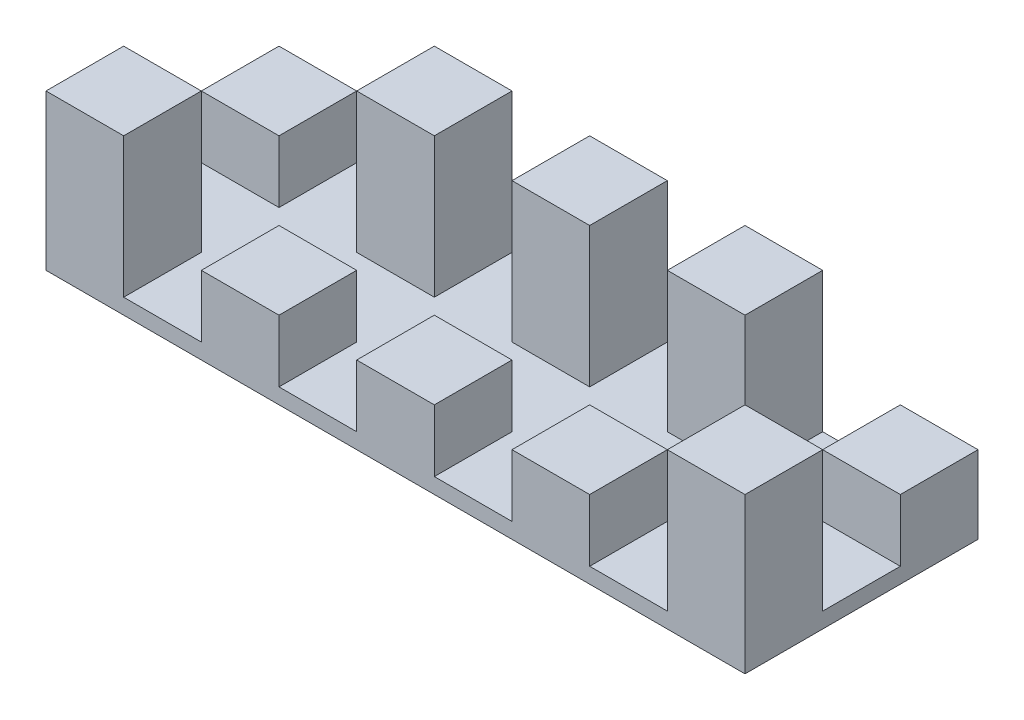
from build123d import *

# Parameters (mm, degrees)
SKETCH2_W             = 500
SKETCH2_H             = 500
BOSS_EXTRUDE1_DEPTH   = 500
BOSS_EXTRUDE1_2_DEPTH = 500
BOSS_EXTRUDE1_3_DEPTH = 500
BOSS_EXTRUDE1_4_DEPTH = 500
BOSS_EXTRUDE1_5_DEPTH = 500
SKETCH2_3_W           = 500
SKETCH2_3_H           = 500
BOSS_EXTRUDE2_DEPTH   = 1000
BOSS_EXTRUDE2_2_DEPTH = 1000
BOSS_EXTRUDE2_3_DEPTH = 1000
BOSS_EXTRUDE2_4_DEPTH = 1000
BOSS_EXTRUDE2_5_DEPTH = 1000
BOSS_EXTRUDE3_DEPTH   = 100


with BuildPart() as part:
    # Sketch2 → Boss-Extrude1 (new body)
    with BuildSketch(Plane(origin=(0, 0, 0), x_dir=(1, 0, 0), z_dir=(0, 1, 0))):
        with Locations((250, 1250)):
            Rectangle(SKETCH2_W, SKETCH2_H)
    extrude(amount=BOSS_EXTRUDE1_DEPTH)



with BuildPart() as body_2:
    # Sketch2 → Boss-Extrude1 2 (new body)
    with BuildSketch(Plane(origin=(0, 0, 0), x_dir=(1, 0, 0), z_dir=(0, 1, 0))):
        with Locations((4250, 1250)):
            Rectangle(SKETCH2_W, SKETCH2_H)
    extrude(amount=BOSS_EXTRUDE1_2_DEPTH)


with BuildPart() as body_3:
    # Sketch2 → Boss-Extrude1 3 (new body)
    with BuildSketch(Plane(origin=(0, 0, 0), x_dir=(1, 0, 0), z_dir=(0, 1, 0))):
        with Locations((1250, 250)):
            Rectangle(SKETCH2_W, SKETCH2_H)
    extrude(amount=BOSS_EXTRUDE1_3_DEPTH)


with BuildPart() as body_4:
    # Sketch2 → Boss-Extrude1 4 (new body)
    with BuildSketch(Plane(origin=(0, 0, 0), x_dir=(1, 0, 0), z_dir=(0, 1, 0))):
        with Locations((2250, 250)):
            Rectangle(SKETCH2_W, SKETCH2_H)
    extrude(amount=BOSS_EXTRUDE1_4_DEPTH)


with BuildPart() as body_5:
    # Sketch2 → Boss-Extrude1 5 (new body)
    with BuildSketch(Plane(origin=(0, 0, 0), x_dir=(1, 0, 0), z_dir=(0, 1, 0))):
        with Locations((3250, 250)):
            Rectangle(SKETCH2_W, SKETCH2_H)
    extrude(amount=BOSS_EXTRUDE1_5_DEPTH)


with BuildPart() as body_6:
    # Sketch2_3 → Boss-Extrude2 (new body)
    with BuildSketch(Plane(origin=(0, 0, 0), x_dir=(1, 0, 0), z_dir=(0, 1, 0))):
        with Locations((1250, 1250)):
            Rectangle(SKETCH2_3_W, SKETCH2_3_H)
    extrude(amount=BOSS_EXTRUDE2_DEPTH)


with BuildPart() as body_7:
    # Sketch2_3 → Boss-Extrude2 2 (new body)
    with BuildSketch(Plane(origin=(0, 0, 0), x_dir=(1, 0, 0), z_dir=(0, 1, 0))):
        with Locations((2250, 1250)):
            Rectangle(SKETCH2_3_W, SKETCH2_3_H)
    extrude(amount=BOSS_EXTRUDE2_2_DEPTH)


with BuildPart() as body_8:
    # Sketch2_3 → Boss-Extrude2 3 (new body)
    with BuildSketch(Plane(origin=(0, 0, 0), x_dir=(1, 0, 0), z_dir=(0, 1, 0))):
        with Locations((250, 250)):
            Rectangle(SKETCH2_3_W, SKETCH2_3_H)
    extrude(amount=BOSS_EXTRUDE2_3_DEPTH)


with BuildPart() as body_9:
    # Sketch2_3 → Boss-Extrude2 4 (new body)
    with BuildSketch(Plane(origin=(0, 0, 0), x_dir=(1, 0, 0), z_dir=(0, 1, 0))):
        with Locations((3250, 1250)):
            Rectangle(SKETCH2_3_W, SKETCH2_3_H)
    extrude(amount=BOSS_EXTRUDE2_4_DEPTH)


with BuildPart() as body_10:
    # Sketch2_3 → Boss-Extrude2 5 (new body)
    with BuildSketch(Plane(origin=(0, 0, 0), x_dir=(1, 0, 0), z_dir=(0, 1, 0))):
        with Locations((4250, 250)):
            Rectangle(SKETCH2_3_W, SKETCH2_3_H)
    extrude(amount=BOSS_EXTRUDE2_5_DEPTH)


with BuildPart() as part_1:
    add(part.part)

    add(body_2.part)  # Boss-Extrude3 merges body 2

    add(body_3.part)  # Boss-Extrude3 merges body 3

    add(body_4.part)  # Boss-Extrude3 merges body 4

    add(body_5.part)  # Boss-Extrude3 merges body 5

    add(body_6.part)  # Boss-Extrude3 merges body 6

    add(body_7.part)  # Boss-Extrude3 merges body 7

    add(body_8.part)  # Boss-Extrude3 merges body 8

    add(body_9.part)  # Boss-Extrude3 merges body 9

    add(body_10.part)  # Boss-Extrude3 merges body 10
    # Sketch2_4 → Boss-Extrude3 (add)
    with BuildSketch(Plane(origin=(0, 0, 0), x_dir=(1, 0, 0), z_dir=(0, 1, 0))):
        Polygon((1000, 1000), (1000, 1500), (500, 1500), (500, 1000), (0, 1000), (0, 500), (500, 500), (500, 0), (1000, 0), (1000, 500), (1500, 500), (1500, 0), (2000, 0), (2000, 500), (2500, 500), (2500, 0), (3000, 0), (3000, 500), (3500, 500), (3500, 0), (4000, 0), (4000, 500), (4500, 500), (4500, 1000), (4000, 1000), (4000, 1500), (3500, 1500), (3500, 1000), (3000, 1000), (3000, 1500), (2500, 1500), (2500, 1000), (2000, 1000), (2000, 1500), (1500, 1500), (1500, 1000), align=None)
    extrude(amount=BOSS_EXTRUDE3_DEPTH)


solid = part_1.part
